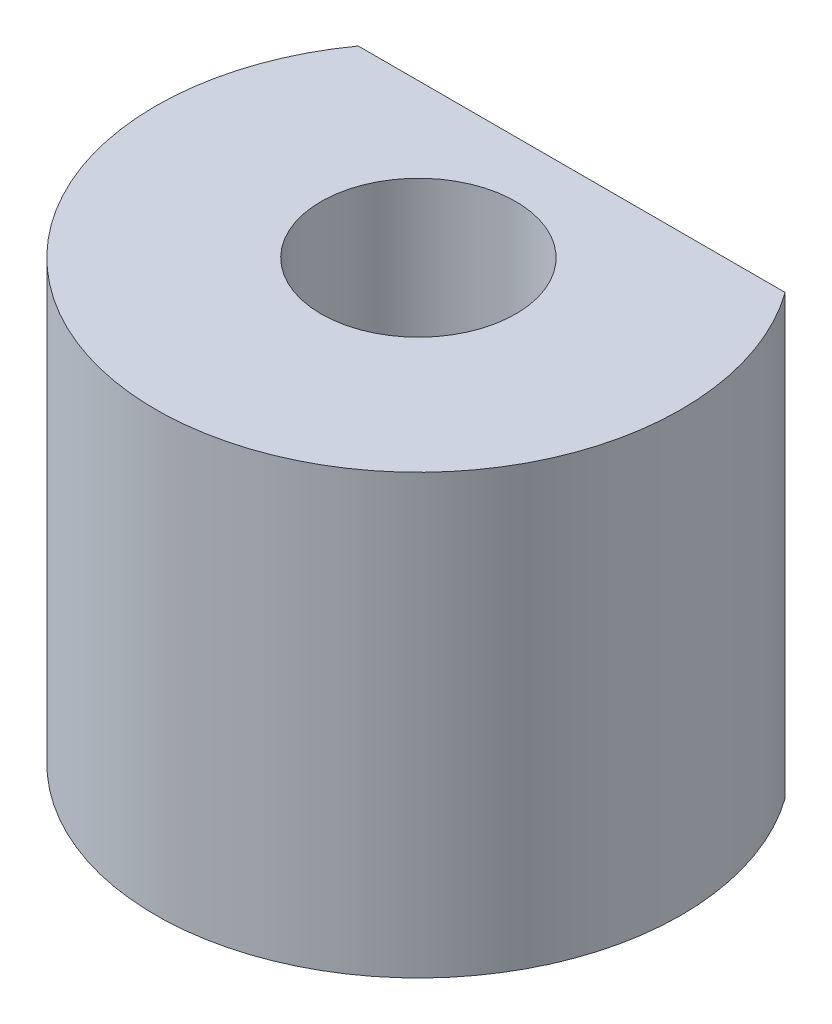
from build123d import *

# Parameters (mm, degrees)
SKETCH1_R           = 2.223760431
BOSS_EXTRUDE1_DEPTH = 10


with BuildPart() as part:
    # Sketch1 → Boss-Extrude1 (new body)
    with BuildSketch(Plane(origin=(0, 0, 0), x_dir=(1, 0, 0), z_dir=(0, 1, 0))):
        with BuildLine():
            Line((4.873397172, 3.5), (-4.873397172, 3.5))
            ThreePointArc((-4.873397172, 3.5), (-1.838425545, -5.711408891), (6, 0))
            ThreePointArc((6, 0), (5.711408891, 1.838425545), (4.873397172, 3.5))
        make_face()
        Circle(SKETCH1_R, mode=Mode.SUBTRACT)
    extrude(amount=BOSS_EXTRUDE1_DEPTH)


solid = part.part
